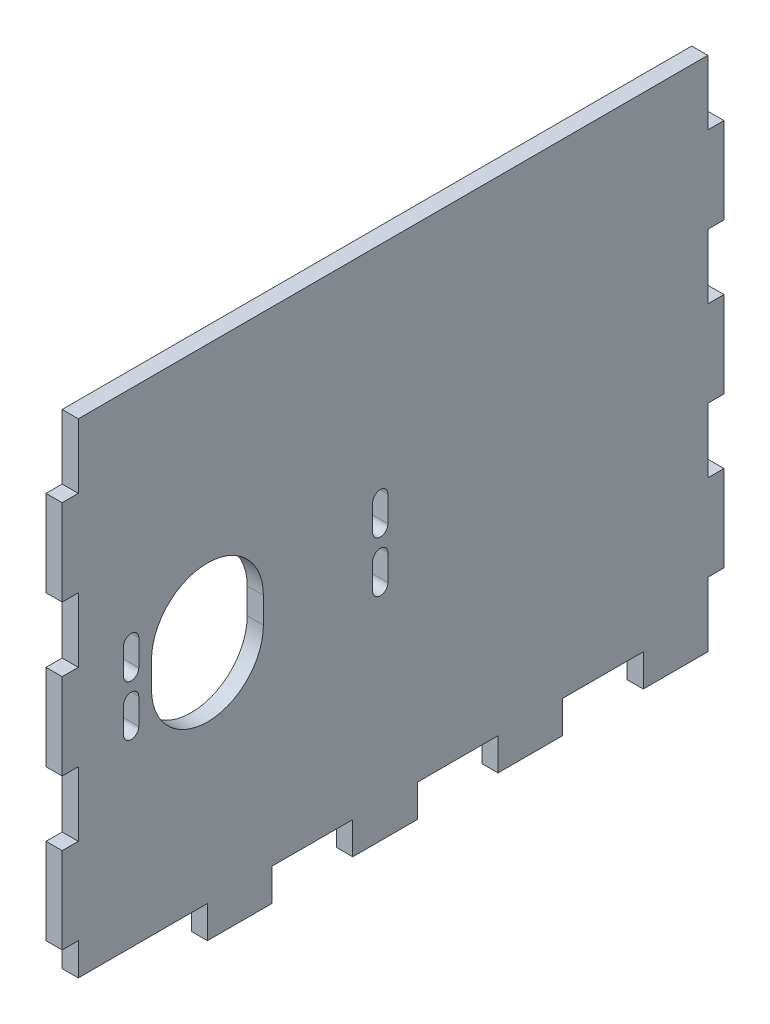
from build123d import *

# Parameters (mm, degrees)
SKETCH1_W               = 44.958
SKETCH1_H               = 304.8
BOSS_EXTRUDE1_DEPTH     = 3.175
BOSS_EXTRUDE2_DEPTH     = 3.175
SKETCH3_W               = 123.825
SKETCH3_H               = 6.35
BOSS_EXTRUDE3_DEPTH     = 41.783
SKETCH8_W               = 3.175
SKETCH8_H               = 213.451350416
CUT_EXTRUDE4_DEPTH      = 1
CUT_EXTRUDE4_DEPTH_BACK = 131.175
SKETCH6_W               = 3.175
SKETCH6_H               = 12.7
CUT_EXTRUDE5_DEPTH      = 3.175
SKETCH4_3_W             = 6.35
SKETCH4_3_H             = 15.875
SKETCH4_3_H_2           = 5.588
SKETCH4_3_H_3           = 7.112
CUT_EXTRUDE6_DEPTH      = 6.35


with BuildPart() as part:
    # Sketch1 → Boss-Extrude1 (new body)
    with BuildSketch(Plane.XY):
        with Locations((-6.477, 3.048)):
            Rectangle(SKETCH1_W, SKETCH1_H)
        with BuildLine():
            Line((-3.302, 133.858), (-3.302, -143.002))
            Line((-3.302, -143.002), (3.302, -143.002))
            Line((3.302, -143.002), (3.302, 143.002))
            Line((3.302, 143.002), (-16.256, 143.002))
            Line((-16.256, 143.002), (-16.256, 136.398))
            Line((-16.256, 136.398), (-5.842, 136.398))
            ThreePointArc((-5.842, 136.398), (-4.045948776, 135.654051224), (-3.302, 133.858))
        make_face(mode=Mode.SUBTRACT)
    extrude(amount=BOSS_EXTRUDE1_DEPTH)

    # Sketch2 → Boss-Extrude2 (add)
    with BuildSketch(Plane(origin=(16.002, 0, 0), x_dir=(0, 0, -1), z_dir=(1, 0, 0))):
        Polygon((123.825, -47.752), (-3.175, -47.752), (-3.175, -149.352), (123.825, -149.352), (123.825, -136.652), (127, -136.652), (127, -119.718666667), (123.825, -119.718666667), (123.825, -107.018666667), (127, -107.018666667), (127, -90.085333333), (123.825, -90.085333333), (123.825, -77.385333333), (127, -77.385333333), (127, -60.452), (123.825, -60.452), align=None)
        with BuildLine():
            ThreePointArc((11.9, -106.092), (10.4, -107.592), (8.9, -106.092))
            Line((8.9, -106.092), (8.9, -101.012))
            ThreePointArc((8.9, -101.012), (10.4, -99.512), (11.9, -101.012))
            Line((11.9, -101.012), (11.9, -106.092))
        make_face(mode=Mode.SUBTRACT)
        with BuildLine():
            ThreePointArc((60.9, -106.092), (59.4, -107.592), (57.9, -106.092))
            Line((57.9, -106.092), (57.9, -101.012))
            ThreePointArc((57.9, -101.012), (59.4, -99.512), (60.9, -101.012))
            Line((60.9, -101.012), (60.9, -106.092))
        make_face(mode=Mode.SUBTRACT)
        with BuildLine():
            Line((8.9, -96.092), (8.9, -91.012))
            ThreePointArc((8.9, -91.012), (10.4, -89.512), (11.9, -91.012))
            Line((11.9, -91.012), (11.9, -96.092))
            ThreePointArc((11.9, -96.092), (10.4, -97.592), (8.9, -96.092))
        make_face(mode=Mode.SUBTRACT)
        with BuildLine():
            ThreePointArc((36.4, -101.092), (25.4, -112.092), (14.4, -101.092))
            Line((14.4, -101.092), (14.4, -96.012))
            ThreePointArc((14.4, -96.012), (25.4, -85.012), (36.4, -96.012))
            Line((36.4, -96.012), (36.4, -101.092))
        make_face(mode=Mode.SUBTRACT)
        with BuildLine():
            ThreePointArc((57.9, -91.012), (59.4, -89.512), (60.9, -91.012))
            Line((60.9, -91.012), (60.9, -96.092))
            ThreePointArc((60.9, -96.092), (59.4, -97.592), (57.9, -96.092))
            Line((57.9, -96.092), (57.9, -91.012))
        make_face(mode=Mode.SUBTRACT)
    extrude(amount=-BOSS_EXTRUDE2_DEPTH)

    # Sketch3 → Boss-Extrude3 (add)
    with BuildSketch(Plane.ZY.offset(-12.827)):
        with Locations((-61.9125, -146.177)):
            Rectangle(SKETCH3_W, SKETCH3_H)
    extrude(amount=BOSS_EXTRUDE3_DEPTH)

    # Sketch8 → Cut-Extrude4 (cut, two sides)
    with BuildSketch(Plane.XY.offset(3.175)) as cut_extrude4_sk:
        Polygon((-28.956, -149.352), (12.827, -149.352), (12.827, -47.752), (12.827, 155.448), (-28.956, 155.448), align=None)
        with BuildLine():
            Line((-16.256, 136.398), (-16.256, 143.002))
            Line((-16.256, 143.002), (3.302, 143.002))
            Line((3.302, 143.002), (3.302, -143.002))
            Line((3.302, -143.002), (-3.302, -143.002))
            Line((-3.302, -143.002), (-3.302, 133.858))
            ThreePointArc((-3.302, 133.858), (-4.045948776, 135.654051224), (-5.842, 136.398))
            Line((-5.842, 136.398), (-16.256, 136.398))
        make_face(mode=Mode.SUBTRACT)
        Polygon((-54.223542679, -149.352), (-28.956, -149.352), (-28.956, 155.448), (12.827, 155.448), (12.827, 165.699350416), (-54.223542679, 165.699350416), align=None)
        with Locations((14.4145, 58.973675208)):
            Rectangle(SKETCH8_W, SKETCH8_H)
    extrude(amount=CUT_EXTRUDE4_DEPTH, mode=Mode.SUBTRACT)
    extrude(cut_extrude4_sk.sketch, amount=-CUT_EXTRUDE4_DEPTH_BACK, mode=Mode.SUBTRACT)

    # Sketch6 → Cut-Extrude5 (cut)
    with BuildSketch(Plane.XY.offset(3.175)):
        with Locations((14.4145, -54.102)):
            Rectangle(SKETCH6_W, SKETCH6_H)
        with Locations((14.4145, -83.735333333)):
            Rectangle(SKETCH6_W, SKETCH6_H)
        with Locations((14.4145, -113.368666667)):
            Rectangle(SKETCH6_W, SKETCH6_H)
        with Locations((14.4145, -143.002)):
            Rectangle(SKETCH6_W, SKETCH6_H)
    extrude(amount=-CUT_EXTRUDE5_DEPTH, mode=Mode.SUBTRACT)

    # Sketch4_3 → Cut-Extrude6 (cut)
    with BuildSketch(Plane.XZ.offset(149.352)):
        with Locations((12.827, -103.1875)):
            Rectangle(SKETCH4_3_W, SKETCH4_3_H)
        with Locations((12.827, -74.6125)):
            Rectangle(SKETCH4_3_W, SKETCH4_3_H)
        with Locations((12.827, -46.0375)):
            Rectangle(SKETCH4_3_W, SKETCH4_3_H)
        with Locations((12.827, -17.4625)):
            Rectangle(SKETCH4_3_W, SKETCH4_3_H)
        with Locations((12.827, 0.381)):
            Rectangle(SKETCH4_3_W, SKETCH4_3_H_2)
        with Locations((12.827, -5.969)):
            Rectangle(SKETCH4_3_W, SKETCH4_3_H_3)
    extrude(amount=-CUT_EXTRUDE6_DEPTH, mode=Mode.SUBTRACT)


solid = part.part
